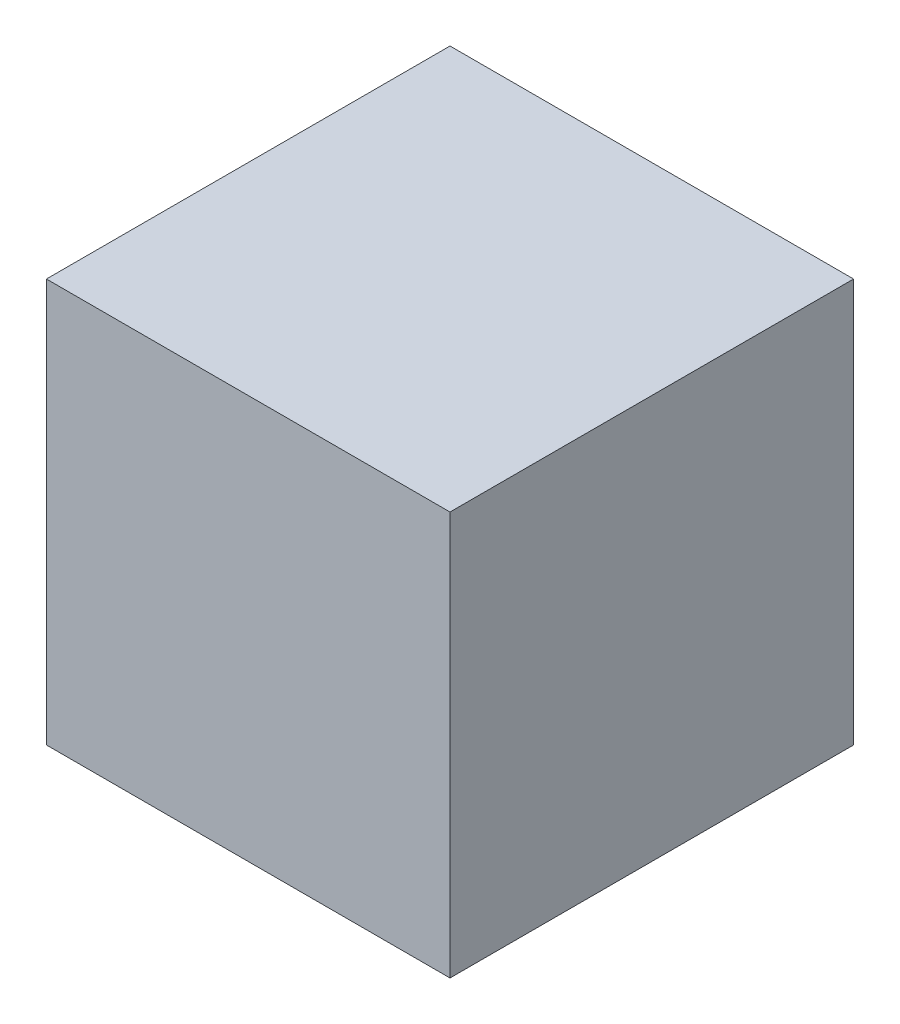
from build123d import *

# Parameters (mm, degrees)
ZY_BOUNDING_W       = 609.6
ZY_BOUNDING_H       = 609.6
BOSS_EXTRUDE1_DEPTH = 304.8


with BuildPart() as part:
    # zy bounding → Boss-Extrude1 (new body, symmetric)
    with BuildSketch(Plane(origin=(0, 0, 0), x_dir=(0, 0, -1), z_dir=(1, 0, 0))):
        with Locations((0, 304.8)):
            Rectangle(ZY_BOUNDING_W, ZY_BOUNDING_H)
    extrude(amount=BOSS_EXTRUDE1_DEPTH, both=True)


solid = part.part
